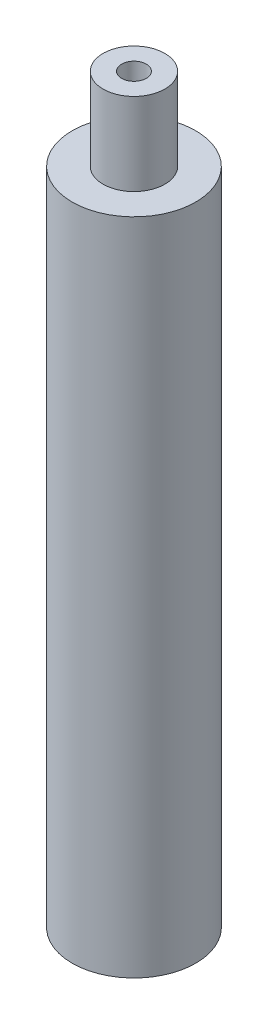
from build123d import *

# Parameters (mm, degrees)
SKETCH1_R           = 9.525
BOSS_EXTRUDE2_DEPTH = 101.6
SKETCH3_R           = 4.7625
BOSS_EXTRUDE3_DEPTH = 12.7
SKETCH14_R          = 5.7546875
CUT_EXTRUDE4_DEPTH  = 25.4
SKETCH17_R          = 1.905
CUT_EXTRUDE5_DEPTH  = 89.9


with BuildPart() as part:
    # Sketch1 → Boss-Extrude2 (new body)
    with BuildSketch(Plane(origin=(0, 0, 0), x_dir=(1, 0, 0), z_dir=(0, 1, 0))):
        Circle(SKETCH1_R)
    extrude(amount=BOSS_EXTRUDE2_DEPTH)

    # Sketch3 → Boss-Extrude3 (add)
    with BuildSketch(Plane(origin=(0, 101.6, 0), x_dir=(1, 0, 0), z_dir=(0, 1, 0))):
        Circle(SKETCH3_R)
    extrude(amount=BOSS_EXTRUDE3_DEPTH)

    # Sketch14 → Cut-Extrude4 (cut)
    with BuildSketch(Plane.XZ):
        Circle(SKETCH14_R)
    extrude(amount=-CUT_EXTRUDE4_DEPTH, mode=Mode.SUBTRACT)

    # Sketch17 → Cut-Extrude5 (cut, through all)
    with BuildSketch(Plane.XZ.offset(-25.4)):
        Circle(SKETCH17_R)
    extrude(amount=-CUT_EXTRUDE5_DEPTH, mode=Mode.SUBTRACT)


solid = part.part
